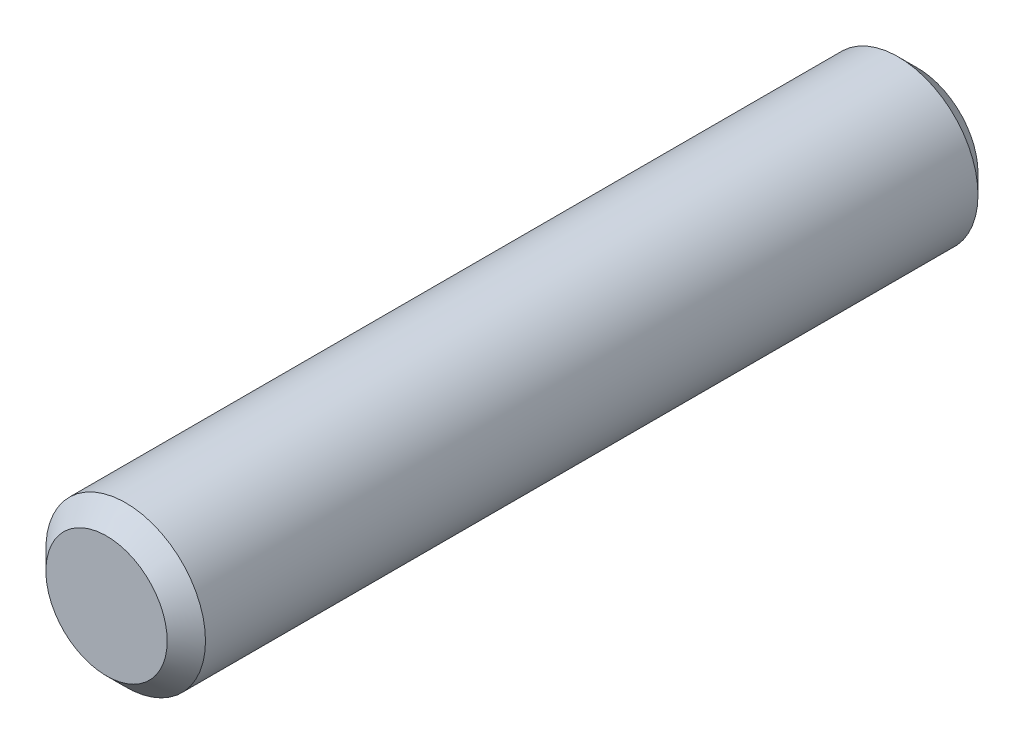
from build123d import *

# Parameters (mm, degrees)
SKETCH1_R           = 12.5
BOSS_EXTRUDE1_DEPTH = 127
CHAMFER1_SIZE       = 3


with BuildPart() as part:
    # Sketch1 → Boss-Extrude1 (new body)
    with BuildSketch(Plane.XY):
        Circle(SKETCH1_R)
    extrude(amount=BOSS_EXTRUDE1_DEPTH)

    # Chamfer1
    chamfer1_edges = [part.edges().sort_by_distance(p)[0] for p in [
        (-12.5, 0, 0),
        (-12.5, 0, 127),
    ]]
    chamfer(chamfer1_edges, length=CHAMFER1_SIZE)


solid = part.part
